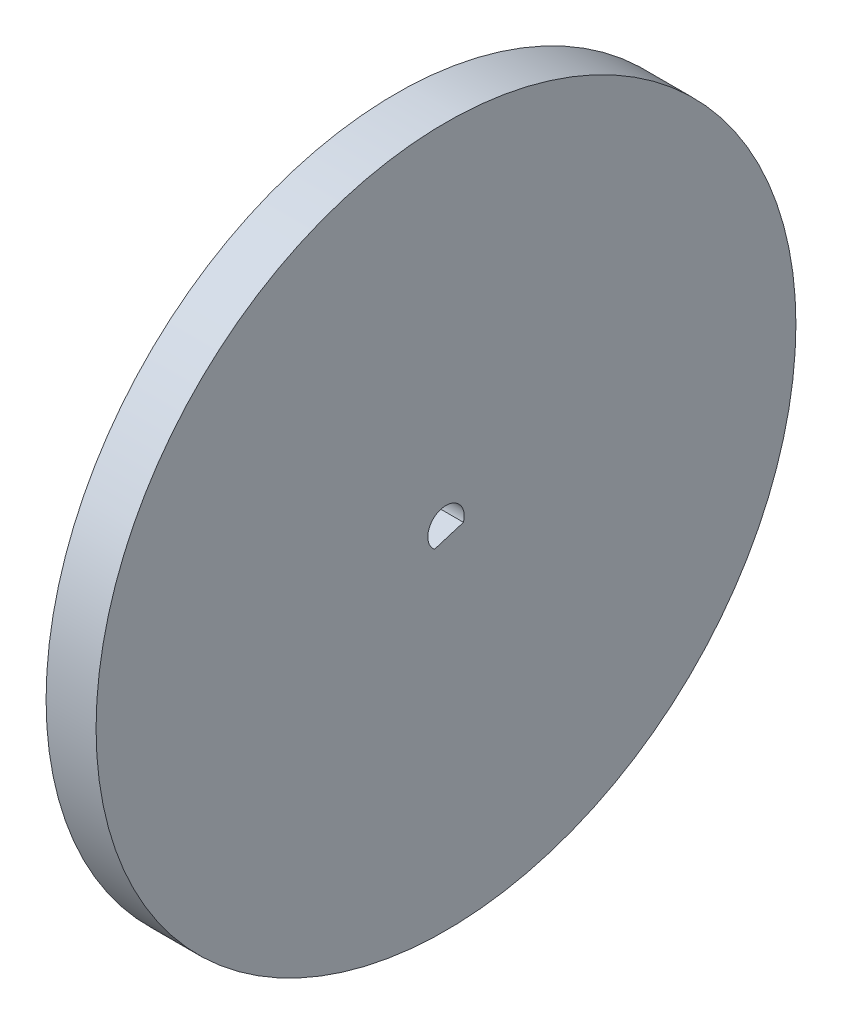
from build123d import *

# Parameters (mm, degrees)
SKETCH1_R           = 44.45
BOSS_EXTRUDE1_DEPTH = 6.35
CUT_EXTRUDE1_DEPTH  = 7.35


with BuildPart() as part:
    # Sketch1 → Boss-Extrude1 (new body)
    with BuildSketch(Plane(origin=(0, 0, 0), x_dir=(0, 0, -1), z_dir=(1, 0, 0))):
        Circle(SKETCH1_R)
    extrude(amount=BOSS_EXTRUDE1_DEPTH)

    # Sketch5 → Cut-Extrude1 (cut, through all)
    with BuildSketch(Plane(origin=(6.35, 0, 0), x_dir=(0, 0, -1), z_dir=(1, 0, 0))):
        with BuildLine():
            Line((-1.467338899, -1.785913356), (2.216714185, -0.654788654))
            ThreePointArc((2.216714185, -0.654788654), (-0.678418457, 2.209596877), (-1.467338899, -1.785913356))
        make_face()
    extrude(amount=-CUT_EXTRUDE1_DEPTH, mode=Mode.SUBTRACT)


solid = part.part
